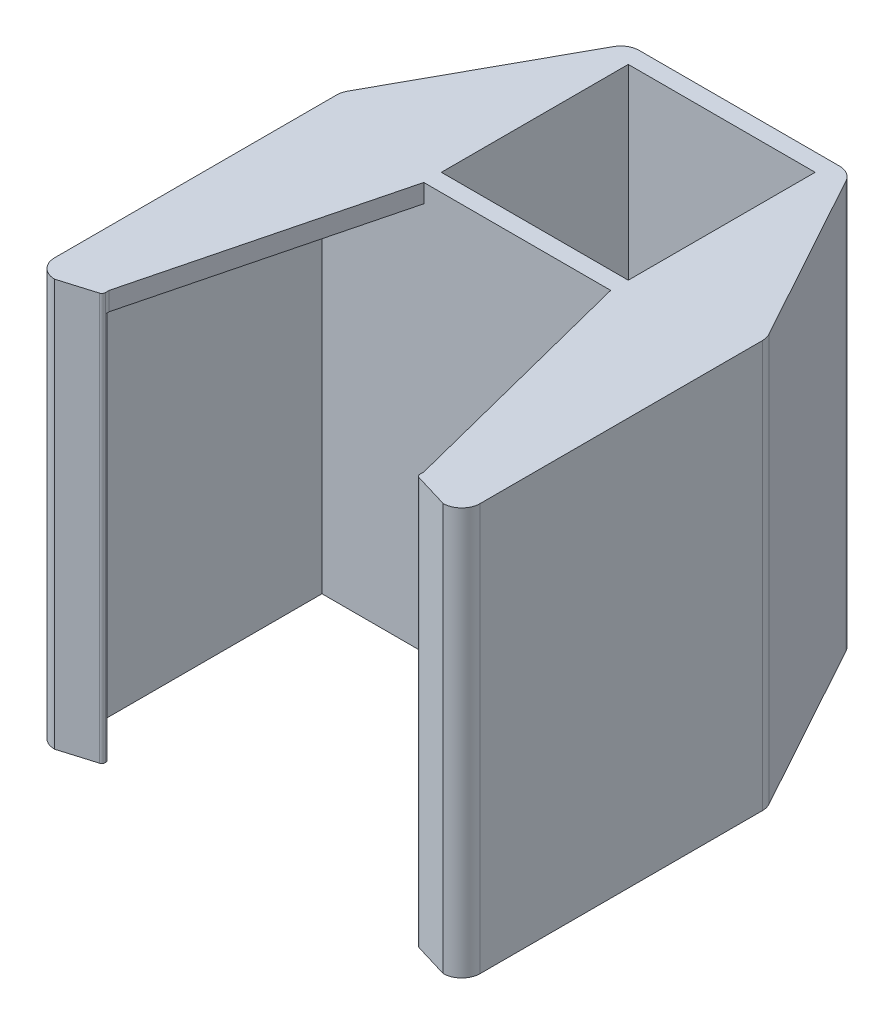
from build123d import *

# Parameters (mm, degrees)
SALIENTE_EXTRUIR1_DEPTH             = 2
SALIENTE_EXTRUIR2_DEPTH             = 42
CORTAR_EXTRUIR1_REACH               = 46.1
CROQUIS3_W                          = 42
CROQUIS3_H                          = 27.1
CORTAR_EXTRUIR2_REACH               = 46.1
CROQUIS4_W                          = 27.1
CROQUIS4_H                          = 42
CROQUIS5_W                          = 20.2
CROQUIS5_H                          = 20.2
CORTAR_EXTRUIR3_DEPTH               = 45
DI_METRO_DE_TALADRO_4_2_4_2_1_D     = 4.2
DI_METRO_DE_TALADRO_4_2_4_2_1_DEPTH = 1.9
REDONDEO1_R                         = 0.4
REDONDEO2_R                         = 1.9
REDONDEO3_R                         = 2


with BuildPart() as part:
    # Croquis1 → Saliente-Extruir1 (new body)
    with BuildSketch(Plane(origin=(0, -115.999797701, 0), x_dir=(1, 0, 0), z_dir=(0, 1, 0))):
        with BuildLine():
            Line((10.1, -331), (17, -358.1))
            Line((17, -358.1), (17, -358.8))
            Line((17, -358.8), (21, -360))
            ThreePointArc((21, -360), (22.414213562, -359.414213562), (23, -358))
            Line((23, -358), (23, -327))
            Line((23, -327), (12, -307))
            Line((12, -307), (-12, -307))
            Line((-12, -307), (-23, -327))
            Line((-23, -327), (-23, -358))
            ThreePointArc((-23, -358), (-22.414213562, -359.414213562), (-21, -360))
            Line((-21, -360), (-17, -358.8))
            Line((-17, -358.8), (-17, -358.1))
            Line((-17, -358.1), (-10.1, -331))
            Line((-10.1, -331), (10.1, -331))
        make_face()
    extrude(amount=-SALIENTE_EXTRUIR1_DEPTH)

    # Croquis2 → Saliente-Extruir2 (add)
    with BuildSketch(Plane.XZ.offset(117.999797701)):
        with BuildLine():
            Line((-17, 331), (17, 331))
            Line((17, 331), (17, 358.8))
            Line((17, 358.8), (21, 360))
            ThreePointArc((21, 360), (22.414213562, 359.414213562), (23, 358))
            Line((23, 358), (23, 327))
            Line((23, 327), (12, 307))
            Line((12, 307), (-12, 307))
            Line((-12, 307), (-23, 327))
            Line((-23, 327), (-23, 358))
            ThreePointArc((-23, 358), (-22.414213562, 359.414213562), (-21, 360))
            Line((-21, 360), (-17, 358.8))
            Line((-17, 358.8), (-17, 331))
        make_face()
    extrude(amount=SALIENTE_EXTRUIR2_DEPTH)

    # Croquis3 → Cortar-Extruir1 (cut, up to next)
    with BuildSketch(Plane(origin=(-21.1, 0, 0), x_dir=(0, -1, 0), z_dir=(-1, 0, 0)), mode=Mode.PRIVATE) as cortar_extruir1_sk1:
        with Locations((138.999797701, 344.55)):
            Rectangle(CROQUIS3_W, CROQUIS3_H)
    cortar_extruir1_tool1 = extrude(cortar_extruir1_sk1.sketch, amount=-CORTAR_EXTRUIR1_REACH, mode=Mode.PRIVATE) & part.part
    add(cortar_extruir1_tool1.solids().sort_by_distance((-21.1, -138.999798, 344.55))[0], mode=Mode.SUBTRACT)

    # Croquis4 → Cortar-Extruir2 (cut, up to next)
    with BuildSketch(Plane(origin=(21.1, 0, 0), x_dir=(0, 0, -1), z_dir=(1, 0, 0)), mode=Mode.PRIVATE) as cortar_extruir2_sk1:
        with Locations((-344.55, -138.999797701)):
            Rectangle(CROQUIS4_W, CROQUIS4_H)
    cortar_extruir2_tool1 = extrude(cortar_extruir2_sk1.sketch, amount=-CORTAR_EXTRUIR2_REACH, mode=Mode.PRIVATE) & part.part
    add(cortar_extruir2_tool1.solids().sort_by_distance((21.1, -138.999798, 344.55))[0], mode=Mode.SUBTRACT)

    # Croquis5 → Cortar-Extruir3 (cut, through all)
    with BuildSketch(Plane(origin=(0, -115.999797701, 0), x_dir=(-1, 0, 0), z_dir=(0, 1, 0))):
        with Locations((0, 319)):
            Rectangle(CROQUIS5_W, CROQUIS5_H)
    extrude(amount=-CORTAR_EXTRUIR3_DEPTH, mode=Mode.SUBTRACT)

    # Diámetro de taladro Ø4.2 (4.2)1
    with Locations(Plane(origin=(0, 0, 307), x_dir=(-1, 0, 0), z_dir=(0, 0, -1))):
        with Locations((0, -137.999797701)):
            Hole(DI_METRO_DE_TALADRO_4_2_4_2_1_D / 2, depth=DI_METRO_DE_TALADRO_4_2_4_2_1_DEPTH)

    # Redondeo1
    redondeo1_edges = [part.edges().sort_by_distance(p)[0] for p in [
        (-17, -137.999797701, 358.8),
        (17, -137.999797701, 358.8),
        (-17, -138.999797701, 358.1),
        (17, -138.999797701, 358.1),
    ]]
    fillet(redondeo1_edges, radius=REDONDEO1_R)

    # Redondeo2
    redondeo2_edges = [part.edges().sort_by_distance(p)[0] for p in [
        (-21.1, -138.999797701, 358.1),
        (21.1, -138.999797701, 358.1),
    ]]
    fillet(redondeo2_edges, radius=REDONDEO2_R)

    # Redondeo3
    redondeo3_edges = [part.edges().sort_by_distance(p)[0] for p in [
        (-23, -137.999797701, 327),
        (-12, -137.999797701, 307),
        (12, -137.999797701, 307),
        (23, -137.999797701, 327),
    ]]
    fillet(redondeo3_edges, radius=REDONDEO3_R)


solid = part.part
